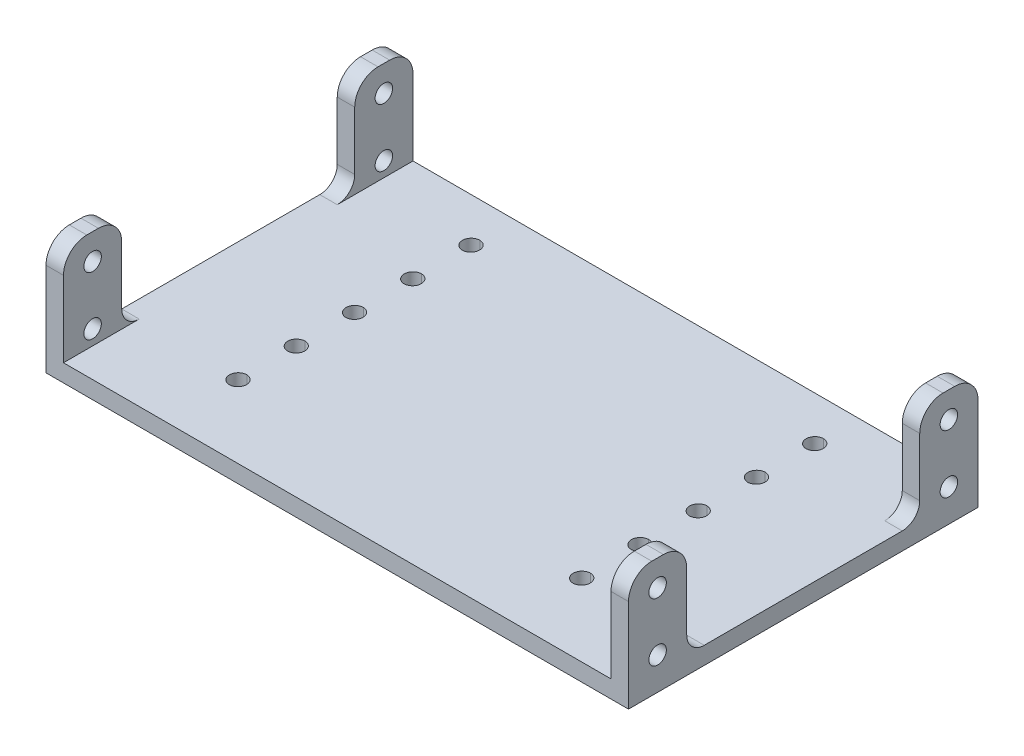
from build123d import *

# Parameters (mm, degrees)
SKETCH1_W           = 100
SKETCH1_H           = 60
SKETCH1_R           = 1.5
BOSS_EXTRUDE1_DEPTH = 3
SKETCH3_R           = 1.5
SKETCH3_W           = 10
SKETCH3_H           = 17
BOSS_EXTRUDE2_DEPTH = 3
FILLET1_R           = 3
FILLET2_R           = 4


with BuildPart() as part:
    # Sketch1 → Boss-Extrude1 (new body)
    with BuildSketch(Plane(origin=(0, 0, 0), x_dir=(1, 0, 0), z_dir=(0, 1, 0))):
        Rectangle(SKETCH1_W, SKETCH1_H)
        with Locations((-29.462365137, -17.533964752)):
            Circle(SKETCH1_R, mode=Mode.SUBTRACT)
        with Locations((-29.462365137, -7.533964752)):
            Circle(SKETCH1_R, mode=Mode.SUBTRACT)
        with Locations((-29.462365137, 2.466035248)):
            Circle(SKETCH1_R, mode=Mode.SUBTRACT)
        with Locations((-29.462365137, 12.466035248)):
            Circle(SKETCH1_R, mode=Mode.SUBTRACT)
        with Locations((-29.462365137, 22.466035248)):
            Circle(SKETCH1_R, mode=Mode.SUBTRACT)
        with Locations((29.537634863, 22.466035248)):
            Circle(SKETCH1_R, mode=Mode.SUBTRACT)
        with Locations((29.537634863, 12.466035248)):
            Circle(SKETCH1_R, mode=Mode.SUBTRACT)
        with Locations((29.537634863, 2.466035248)):
            Circle(SKETCH1_R, mode=Mode.SUBTRACT)
        with Locations((29.537634863, -7.533964752)):
            Circle(SKETCH1_R, mode=Mode.SUBTRACT)
        with Locations((29.537634863, -17.533964752)):
            Circle(SKETCH1_R, mode=Mode.SUBTRACT)
    boss_extrude1 = extrude(amount=BOSS_EXTRUDE1_DEPTH)

    # Sketch3 → Boss-Extrude2 (add)
    with BuildSketch(Plane(origin=(50, 0, 0), x_dir=(0, 0, -1), z_dir=(1, 0, 0))):
        Polygon((-30, 3), (-25, 3), (-20, 3), (-20, 20), (-30, 20), align=None)
        with Locations((-25, 5.56)):
            Circle(SKETCH3_R, mode=Mode.SUBTRACT)
        with Locations((-25, 15.56)):
            Circle(SKETCH3_R, mode=Mode.SUBTRACT)
        with Locations((25, 11.5)):
            Rectangle(SKETCH3_W, SKETCH3_H)
        with Locations((25, 5.56)):
            Circle(SKETCH3_R, mode=Mode.SUBTRACT)
        with Locations((25, 15.56)):
            Circle(SKETCH3_R, mode=Mode.SUBTRACT)
    boss_extrude2 = extrude(amount=-BOSS_EXTRUDE2_DEPTH)

    # Mirror1: Boss-Extrude1, Boss-Extrude2 across plane
    add(boss_extrude1.mirror(Plane(origin=(0, 0, 0), x_dir=(0, 0, 1), z_dir=(1, 0, 0))))
    add(boss_extrude2.mirror(Plane(origin=(0, 0, 0), x_dir=(0, 0, 1), z_dir=(1, 0, 0))))

    # Fillet1
    fillet1_edges = [part.edges().sort_by_distance(p)[0] for p in [
        (48.5, 3, 20),
        (48.5, 3, -20),
        (-48.5, 3, 20),
        (-48.5, 3, -20),
    ]]
    fillet(fillet1_edges, radius=FILLET1_R)

    # Fillet2
    fillet2_edges = [part.edges().sort_by_distance(p)[0] for p in [
        (-48.5, 20, 30),
        (-48.5, 20, 20),
        (-48.5, 20, -20),
        (-48.5, 20, -30),
        (48.5, 20, -20),
        (48.5, 20, -30),
        (48.5, 20, 30),
        (48.5, 20, 20),
    ]]
    fillet(fillet2_edges, radius=FILLET2_R)


solid = part.part
